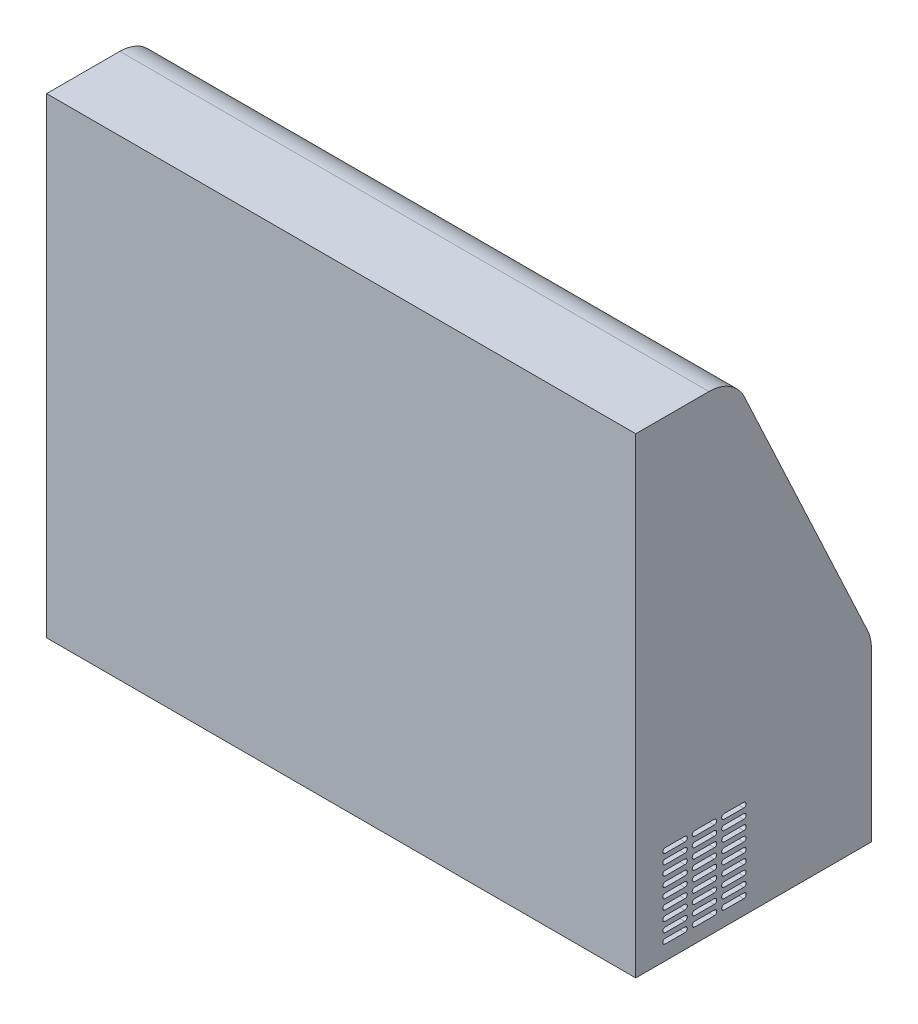
from build123d import *

# Parameters (mm, degrees)
SKETCH1_W               = 762
SKETCH1_H               = 609.6
BOSS_EXTRUDE1_DEPTH     = 304.8
SKETCH6_W               = 63.5
SKETCH6_H               = 122.2375
CUT_EXTRUDE3_DEPTH      = 12.7
CUT_EXTRUDE4_DEPTH      = 763
SKETCH8_W               = 549.402
SKETCH8_H               = 341.376
CUT_EXTRUDE5_DEPTH      = 50.8
CUT_EXTRUDE6_DEPTH      = 50.8
CUT_EXTRUDE7_DEPTH      = 50.8
CUT_EXTRUDE9_DEPTH      = 368.3
CUT_EXTRUDE9_DEPTH_BACK = 368.3


with BuildPart() as part:
    # Sketch1 → Boss-Extrude1 (new body)
    with BuildSketch(Plane.XY):
        Rectangle(SKETCH1_W, SKETCH1_H)
    extrude(amount=BOSS_EXTRUDE1_DEPTH)

    # Sketch6 → Cut-Extrude3 (cut)
    with BuildSketch(Plane(origin=(0, 0, 0), x_dir=(-1, 0, 0), z_dir=(0, 0, -1))):
        with Locations((289.814, -197.305909488)):
            Rectangle(SKETCH6_W, SKETCH6_H)
    extrude(amount=-CUT_EXTRUDE3_DEPTH, mode=Mode.SUBTRACT)

    # Sketch7 → Cut-Extrude4 (cut, through all)
    with BuildSketch(Plane(origin=(381, 0, 0), x_dir=(0, 0, -1), z_dir=(1, 0, 0))):
        with BuildLine():
            Line((-210.15264161, 304.8), (0, 304.8))
            Line((0, 304.8), (0, -87.469946307))
            ThreePointArc((0, -87.469946307), (-1.205784317, -76.467502451), (-4.765896488, -65.987364668))
            Line((-4.765896488, -65.987364668), (-164.118538098, 275.482581639))
            ThreePointArc((-164.118538098, 275.482581639), (-182.864138053, 296.848308877), (-210.15264161, 304.8))
        make_face()
    extrude(amount=-CUT_EXTRUDE4_DEPTH, mode=Mode.SUBTRACT)

    # Sketch8 → Cut-Extrude5 (cut)
    with BuildSketch(Plane(origin=(0, -13.627007299, 29.200729927), x_dir=(-1, 0, 0), z_dir=(0, 0.422885465, -0.90618314))):
        with Locations((0, 130.629903118)):
            Rectangle(SKETCH8_W, SKETCH8_H)
    extrude(amount=-CUT_EXTRUDE5_DEPTH, mode=Mode.SUBTRACT)

    # Sketch11 → Cut-Extrude6 (cut)
    with BuildSketch(Plane(origin=(381, 0, 0), x_dir=(0, 0, -1), z_dir=(1, 0, 0))):
        with BuildLine():
            Line((-228.6, -177.8), (-203.2, -177.8))
            ThreePointArc((-203.2, -177.8), (-200.025, -180.975), (-203.2, -184.15))
            Line((-203.2, -184.15), (-228.6, -184.15))
            ThreePointArc((-228.6, -184.15), (-231.775, -180.975), (-228.6, -177.8))
        make_face()
        with BuildLine():
            Line((-190.5, -177.8), (-165.1, -177.8))
            ThreePointArc((-165.1, -177.8), (-161.925, -180.975), (-165.1, -184.15))
            Line((-165.1, -184.15), (-190.5, -184.15))
            ThreePointArc((-190.5, -184.15), (-193.675, -180.975), (-190.5, -177.8))
        make_face()
        with BuildLine():
            Line((-228.6, -190.5), (-203.2, -190.5))
            ThreePointArc((-203.2, -190.5), (-200.025, -193.675), (-203.2, -196.85))
            Line((-203.2, -196.85), (-228.6, -196.85))
            ThreePointArc((-228.6, -196.85), (-231.775, -193.675), (-228.6, -190.5))
        make_face()
        with BuildLine():
            Line((-190.5, -190.5), (-165.1, -190.5))
            ThreePointArc((-165.1, -190.5), (-161.925, -193.675), (-165.1, -196.85))
            Line((-165.1, -196.85), (-190.5, -196.85))
            ThreePointArc((-190.5, -196.85), (-193.675, -193.675), (-190.5, -190.5))
        make_face()
        with BuildLine():
            Line((-228.6, -203.2), (-203.2, -203.2))
            ThreePointArc((-203.2, -203.2), (-200.025, -206.375), (-203.2, -209.55))
            Line((-203.2, -209.55), (-228.6, -209.55))
            ThreePointArc((-228.6, -209.55), (-231.775, -206.375), (-228.6, -203.2))
        make_face()
        with BuildLine():
            Line((-266.7, -177.8), (-241.3, -177.8))
            ThreePointArc((-241.3, -177.8), (-238.125, -180.975), (-241.3, -184.15))
            Line((-241.3, -184.15), (-266.7, -184.15))
            ThreePointArc((-266.7, -184.15), (-269.875, -180.975), (-266.7, -177.8))
        make_face()
        with BuildLine():
            Line((-190.5, -203.2), (-165.1, -203.2))
            ThreePointArc((-165.1, -203.2), (-161.925, -206.375), (-165.1, -209.55))
            Line((-165.1, -209.55), (-190.5, -209.55))
            ThreePointArc((-190.5, -209.55), (-193.675, -206.375), (-190.5, -203.2))
        make_face()
        with BuildLine():
            Line((-228.6, -215.9), (-203.2, -215.9))
            ThreePointArc((-203.2, -215.9), (-200.025, -219.075), (-203.2, -222.25))
            Line((-203.2, -222.25), (-228.6, -222.25))
            ThreePointArc((-228.6, -222.25), (-231.775, -219.075), (-228.6, -215.9))
        make_face()
        with BuildLine():
            Line((-190.5, -215.9), (-165.1, -215.9))
            ThreePointArc((-165.1, -215.9), (-161.925, -219.075), (-165.1, -222.25))
            Line((-165.1, -222.25), (-190.5, -222.25))
            ThreePointArc((-190.5, -222.25), (-193.675, -219.075), (-190.5, -215.9))
        make_face()
        with BuildLine():
            Line((-228.6, -228.6), (-203.2, -228.6))
            ThreePointArc((-203.2, -228.6), (-200.025, -231.775), (-203.2, -234.95))
            Line((-203.2, -234.95), (-228.6, -234.95))
            ThreePointArc((-228.6, -234.95), (-231.775, -231.775), (-228.6, -228.6))
        make_face()
        with BuildLine():
            Line((-190.5, -228.6), (-165.1, -228.6))
            ThreePointArc((-165.1, -228.6), (-161.925, -231.775), (-165.1, -234.95))
            Line((-165.1, -234.95), (-190.5, -234.95))
            ThreePointArc((-190.5, -234.95), (-193.675, -231.775), (-190.5, -228.6))
        make_face()
        with BuildLine():
            Line((-228.6, -241.3), (-203.2, -241.3))
            ThreePointArc((-203.2, -241.3), (-200.025, -244.475), (-203.2, -247.65))
            Line((-203.2, -247.65), (-228.6, -247.65))
            ThreePointArc((-228.6, -247.65), (-231.775, -244.475), (-228.6, -241.3))
        make_face()
        with BuildLine():
            Line((-190.5, -241.3), (-165.1, -241.3))
            ThreePointArc((-165.1, -241.3), (-161.925, -244.475), (-165.1, -247.65))
            Line((-165.1, -247.65), (-190.5, -247.65))
            ThreePointArc((-190.5, -247.65), (-193.675, -244.475), (-190.5, -241.3))
        make_face()
        with BuildLine():
            Line((-228.6, -254), (-203.2, -254))
            ThreePointArc((-203.2, -254), (-200.025, -257.175), (-203.2, -260.35))
            Line((-203.2, -260.35), (-228.6, -260.35))
            ThreePointArc((-228.6, -260.35), (-231.775, -257.175), (-228.6, -254))
        make_face()
        with BuildLine():
            Line((-190.5, -254), (-165.1, -254))
            ThreePointArc((-165.1, -254), (-161.925, -257.175), (-165.1, -260.35))
            Line((-165.1, -260.35), (-190.5, -260.35))
            ThreePointArc((-190.5, -260.35), (-193.675, -257.175), (-190.5, -254))
        make_face()
        with BuildLine():
            Line((-228.6, -266.7), (-203.2, -266.7))
            ThreePointArc((-203.2, -266.7), (-200.025, -269.875), (-203.2, -273.05))
            Line((-203.2, -273.05), (-228.6, -273.05))
            ThreePointArc((-228.6, -273.05), (-231.775, -269.875), (-228.6, -266.7))
        make_face()
        with BuildLine():
            Line((-190.5, -266.7), (-165.1, -266.7))
            ThreePointArc((-165.1, -266.7), (-161.925, -269.875), (-165.1, -273.05))
            Line((-165.1, -273.05), (-190.5, -273.05))
            ThreePointArc((-190.5, -273.05), (-193.675, -269.875), (-190.5, -266.7))
        make_face()
        with BuildLine():
            Line((-228.6, -279.4), (-203.2, -279.4))
            ThreePointArc((-203.2, -279.4), (-200.025, -282.575), (-203.2, -285.75))
            Line((-203.2, -285.75), (-228.6, -285.75))
            ThreePointArc((-228.6, -285.75), (-231.775, -282.575), (-228.6, -279.4))
        make_face()
        with BuildLine():
            Line((-190.5, -279.4), (-165.1, -279.4))
            ThreePointArc((-165.1, -279.4), (-161.925, -282.575), (-165.1, -285.75))
            Line((-165.1, -285.75), (-190.5, -285.75))
            ThreePointArc((-190.5, -285.75), (-193.675, -282.575), (-190.5, -279.4))
        make_face()
        with BuildLine():
            Line((-266.7, -190.5), (-241.3, -190.5))
            ThreePointArc((-241.3, -190.5), (-238.125, -193.675), (-241.3, -196.85))
            Line((-241.3, -196.85), (-266.7, -196.85))
            ThreePointArc((-266.7, -196.85), (-269.875, -193.675), (-266.7, -190.5))
        make_face()
        with BuildLine():
            Line((-266.7, -203.2), (-241.3, -203.2))
            ThreePointArc((-241.3, -203.2), (-238.125, -206.375), (-241.3, -209.55))
            Line((-241.3, -209.55), (-266.7, -209.55))
            ThreePointArc((-266.7, -209.55), (-269.875, -206.375), (-266.7, -203.2))
        make_face()
        with BuildLine():
            Line((-266.7, -215.9), (-241.3, -215.9))
            ThreePointArc((-241.3, -215.9), (-238.125, -219.075), (-241.3, -222.25))
            Line((-241.3, -222.25), (-266.7, -222.25))
            ThreePointArc((-266.7, -222.25), (-269.875, -219.075), (-266.7, -215.9))
        make_face()
        with BuildLine():
            Line((-266.7, -228.6), (-241.3, -228.6))
            ThreePointArc((-241.3, -228.6), (-238.125, -231.775), (-241.3, -234.95))
            Line((-241.3, -234.95), (-266.7, -234.95))
            ThreePointArc((-266.7, -234.95), (-269.875, -231.775), (-266.7, -228.6))
        make_face()
        with BuildLine():
            Line((-266.7, -241.3), (-241.3, -241.3))
            ThreePointArc((-241.3, -241.3), (-238.125, -244.475), (-241.3, -247.65))
            Line((-241.3, -247.65), (-266.7, -247.65))
            ThreePointArc((-266.7, -247.65), (-269.875, -244.475), (-266.7, -241.3))
        make_face()
        with BuildLine():
            Line((-266.7, -254), (-241.3, -254))
            ThreePointArc((-241.3, -254), (-238.125, -257.175), (-241.3, -260.35))
            Line((-241.3, -260.35), (-266.7, -260.35))
            ThreePointArc((-266.7, -260.35), (-269.875, -257.175), (-266.7, -254))
        make_face()
        with BuildLine():
            Line((-266.7, -266.7), (-241.3, -266.7))
            ThreePointArc((-241.3, -266.7), (-238.125, -269.875), (-241.3, -273.05))
            Line((-241.3, -273.05), (-266.7, -273.05))
            ThreePointArc((-266.7, -273.05), (-269.875, -269.875), (-266.7, -266.7))
        make_face()
        with BuildLine():
            Line((-266.7, -279.4), (-241.3, -279.4))
            ThreePointArc((-241.3, -279.4), (-238.125, -282.575), (-241.3, -285.75))
            Line((-241.3, -285.75), (-266.7, -285.75))
            ThreePointArc((-266.7, -285.75), (-269.875, -282.575), (-266.7, -279.4))
        make_face()
    extrude(amount=-CUT_EXTRUDE6_DEPTH, mode=Mode.SUBTRACT)

    # Sketch12 → Cut-Extrude7 (cut)
    with BuildSketch(Plane.XZ.offset(304.8)):
        with BuildLine():
            Line((-289.018463274, 250.918463274), (-263.618463274, 250.918463274))
            ThreePointArc((-263.618463274, 250.918463274), (-260.443463274, 247.743463274), (-263.618463274, 244.568463274))
            Line((-263.618463274, 244.568463274), (-289.018463274, 244.568463274))
            ThreePointArc((-289.018463274, 244.568463274), (-292.193463274, 247.743463274), (-289.018463274, 250.918463274))
        make_face()
        with BuildLine():
            Line((-250.918463274, 250.918463274), (-225.518463274, 250.918463274))
            ThreePointArc((-225.518463274, 250.918463274), (-222.343463274, 247.743463274), (-225.518463274, 244.568463274))
            Line((-225.518463274, 244.568463274), (-250.918463274, 244.568463274))
            ThreePointArc((-250.918463274, 244.568463274), (-254.093463274, 247.743463274), (-250.918463274, 250.918463274))
        make_face()
        with BuildLine():
            Line((-289.018463274, 238.218463274), (-263.618463274, 238.218463274))
            ThreePointArc((-263.618463274, 238.218463274), (-260.443463274, 235.043463274), (-263.618463274, 231.868463274))
            Line((-263.618463274, 231.868463274), (-289.018463274, 231.868463274))
            ThreePointArc((-289.018463274, 231.868463274), (-292.193463274, 235.043463274), (-289.018463274, 238.218463274))
        make_face()
        with BuildLine():
            Line((-250.918463274, 238.218463274), (-225.518463274, 238.218463274))
            ThreePointArc((-225.518463274, 238.218463274), (-222.343463274, 235.043463274), (-225.518463274, 231.868463274))
            Line((-225.518463274, 231.868463274), (-250.918463274, 231.868463274))
            ThreePointArc((-250.918463274, 231.868463274), (-254.093463274, 235.043463274), (-250.918463274, 238.218463274))
        make_face()
        with BuildLine():
            Line((-289.018463274, 225.518463274), (-263.618463274, 225.518463274))
            ThreePointArc((-263.618463274, 225.518463274), (-260.443463274, 222.343463274), (-263.618463274, 219.168463274))
            Line((-263.618463274, 219.168463274), (-289.018463274, 219.168463274))
            ThreePointArc((-289.018463274, 219.168463274), (-292.193463274, 222.343463274), (-289.018463274, 225.518463274))
        make_face()
        with BuildLine():
            Line((-327.118463274, 250.918463274), (-301.718463274, 250.918463274))
            ThreePointArc((-301.718463274, 250.918463274), (-298.543463274, 247.743463274), (-301.718463274, 244.568463274))
            Line((-301.718463274, 244.568463274), (-327.118463274, 244.568463274))
            ThreePointArc((-327.118463274, 244.568463274), (-330.293463274, 247.743463274), (-327.118463274, 250.918463274))
        make_face()
        with BuildLine():
            Line((-250.918463274, 225.518463274), (-225.518463274, 225.518463274))
            ThreePointArc((-225.518463274, 225.518463274), (-222.343463274, 222.343463274), (-225.518463274, 219.168463274))
            Line((-225.518463274, 219.168463274), (-250.918463274, 219.168463274))
            ThreePointArc((-250.918463274, 219.168463274), (-254.093463274, 222.343463274), (-250.918463274, 225.518463274))
        make_face()
        with BuildLine():
            Line((-289.018463274, 212.818463274), (-263.618463274, 212.818463274))
            ThreePointArc((-263.618463274, 212.818463274), (-260.443463274, 209.643463274), (-263.618463274, 206.468463274))
            Line((-263.618463274, 206.468463274), (-289.018463274, 206.468463274))
            ThreePointArc((-289.018463274, 206.468463274), (-292.193463274, 209.643463274), (-289.018463274, 212.818463274))
        make_face()
        with BuildLine():
            Line((-250.918463274, 212.818463274), (-225.518463274, 212.818463274))
            ThreePointArc((-225.518463274, 212.818463274), (-222.343463274, 209.643463274), (-225.518463274, 206.468463274))
            Line((-225.518463274, 206.468463274), (-250.918463274, 206.468463274))
            ThreePointArc((-250.918463274, 206.468463274), (-254.093463274, 209.643463274), (-250.918463274, 212.818463274))
        make_face()
        with BuildLine():
            Line((-289.018463274, 200.118463274), (-263.618463274, 200.118463274))
            ThreePointArc((-263.618463274, 200.118463274), (-260.443463274, 196.943463274), (-263.618463274, 193.768463274))
            Line((-263.618463274, 193.768463274), (-289.018463274, 193.768463274))
            ThreePointArc((-289.018463274, 193.768463274), (-292.193463274, 196.943463274), (-289.018463274, 200.118463274))
        make_face()
        with BuildLine():
            Line((-250.918461565, 200.118465114), (-225.518461565, 200.118465114))
            ThreePointArc((-225.518461565, 200.118465114), (-222.343461565, 196.943465114), (-225.518461565, 193.768465114))
            Line((-225.518461565, 193.768465114), (-250.918461565, 193.768465114))
            ThreePointArc((-250.918461565, 193.768465114), (-254.093461565, 196.943465114), (-250.918461565, 200.118465114))
        make_face()
        with BuildLine():
            Line((-289.018463274, 187.418463274), (-263.618463274, 187.418463274))
            ThreePointArc((-263.618463274, 187.418463274), (-260.443463274, 184.243463274), (-263.618463274, 181.068463274))
            Line((-263.618463274, 181.068463274), (-289.018463274, 181.068463274))
            ThreePointArc((-289.018463274, 181.068463274), (-292.193463274, 184.243463274), (-289.018463274, 187.418463274))
        make_face()
        with BuildLine():
            Line((-250.918463274, 187.418463274), (-225.518463274, 187.418463274))
            ThreePointArc((-225.518463274, 187.418463274), (-222.343463274, 184.243463274), (-225.518463274, 181.068463274))
            Line((-225.518463274, 181.068463274), (-250.918463274, 181.068463274))
            ThreePointArc((-250.918463274, 181.068463274), (-254.093463274, 184.243463274), (-250.918463274, 187.418463274))
        make_face()
        with BuildLine():
            Line((-289.018463274, 174.718463274), (-263.618463274, 174.718463274))
            ThreePointArc((-263.618463274, 174.718463274), (-260.443463274, 171.543463274), (-263.618463274, 168.368463274))
            Line((-263.618463274, 168.368463274), (-289.018463274, 168.368463274))
            ThreePointArc((-289.018463274, 168.368463274), (-292.193463274, 171.543463274), (-289.018463274, 174.718463274))
        make_face()
        with BuildLine():
            Line((-250.918463274, 174.718463274), (-225.518463274, 174.718463274))
            ThreePointArc((-225.518463274, 174.718463274), (-222.343463274, 171.543463274), (-225.518463274, 168.368463274))
            Line((-225.518463274, 168.368463274), (-250.918463274, 168.368463274))
            ThreePointArc((-250.918463274, 168.368463274), (-254.093463274, 171.543463274), (-250.918463274, 174.718463274))
        make_face()
        with BuildLine():
            Line((-289.018463274, 162.018463274), (-263.618463274, 162.018463274))
            ThreePointArc((-263.618463274, 162.018463274), (-260.443463274, 158.843463274), (-263.618463274, 155.668463274))
            Line((-263.618463274, 155.668463274), (-289.018463274, 155.668463274))
            ThreePointArc((-289.018463274, 155.668463274), (-292.193463274, 158.843463274), (-289.018463274, 162.018463274))
        make_face()
        with BuildLine():
            Line((-250.918463274, 162.018463274), (-225.518463274, 162.018463274))
            ThreePointArc((-225.518463274, 162.018463274), (-222.343463274, 158.843463274), (-225.518463274, 155.668463274))
            Line((-225.518463274, 155.668463274), (-250.918463274, 155.668463274))
            ThreePointArc((-250.918463274, 155.668463274), (-254.093463274, 158.843463274), (-250.918463274, 162.018463274))
        make_face()
        with BuildLine():
            Line((-289.018463274, 149.318463274), (-263.618463274, 149.318463274))
            ThreePointArc((-263.618463274, 149.318463274), (-260.443463274, 146.143463274), (-263.618463274, 142.968463274))
            Line((-263.618463274, 142.968463274), (-289.018463274, 142.968463274))
            ThreePointArc((-289.018463274, 142.968463274), (-292.193463274, 146.143463274), (-289.018463274, 149.318463274))
        make_face()
        with BuildLine():
            Line((-250.918463274, 149.318463274), (-225.518463274, 149.318463274))
            ThreePointArc((-225.518463274, 149.318463274), (-222.343463274, 146.143463274), (-225.518463274, 142.968463274))
            Line((-225.518463274, 142.968463274), (-250.918463274, 142.968463274))
            ThreePointArc((-250.918463274, 142.968463274), (-254.093463274, 146.143463274), (-250.918463274, 149.318463274))
        make_face()
        with BuildLine():
            Line((-327.118463274, 238.218463274), (-301.718463274, 238.218463274))
            ThreePointArc((-301.718463274, 238.218463274), (-298.543463274, 235.043463274), (-301.718463274, 231.868463274))
            Line((-301.718463274, 231.868463274), (-327.118463274, 231.868463274))
            ThreePointArc((-327.118463274, 231.868463274), (-330.293463274, 235.043463274), (-327.118463274, 238.218463274))
        make_face()
        with BuildLine():
            Line((-327.118463274, 225.518463274), (-301.718463274, 225.518463274))
            ThreePointArc((-301.718463274, 225.518463274), (-298.543463274, 222.343463274), (-301.718463274, 219.168463274))
            Line((-301.718463274, 219.168463274), (-327.118463274, 219.168463274))
            ThreePointArc((-327.118463274, 219.168463274), (-330.293463274, 222.343463274), (-327.118463274, 225.518463274))
        make_face()
        with BuildLine():
            Line((-327.118463274, 212.818463274), (-301.718463274, 212.818463274))
            ThreePointArc((-301.718463274, 212.818463274), (-298.543463274, 209.643463274), (-301.718463274, 206.468463274))
            Line((-301.718463274, 206.468463274), (-327.118463274, 206.468463274))
            ThreePointArc((-327.118463274, 206.468463274), (-330.293463274, 209.643463274), (-327.118463274, 212.818463274))
        make_face()
        with BuildLine():
            Line((-327.118463274, 200.118463274), (-301.718463274, 200.118463274))
            ThreePointArc((-301.718463274, 200.118463274), (-298.543463274, 196.943463274), (-301.718463274, 193.768463274))
            Line((-301.718463274, 193.768463274), (-327.118463274, 193.768463274))
            ThreePointArc((-327.118463274, 193.768463274), (-330.293463274, 196.943463274), (-327.118463274, 200.118463274))
        make_face()
        with BuildLine():
            Line((-327.118463274, 187.418463274), (-301.718463274, 187.418463274))
            ThreePointArc((-301.718463274, 187.418463274), (-298.543463274, 184.243463274), (-301.718463274, 181.068463274))
            Line((-301.718463274, 181.068463274), (-327.118463274, 181.068463274))
            ThreePointArc((-327.118463274, 181.068463274), (-330.293463274, 184.243463274), (-327.118463274, 187.418463274))
        make_face()
        with BuildLine():
            Line((-327.118463274, 174.718463274), (-301.718463274, 174.718463274))
            ThreePointArc((-301.718463274, 174.718463274), (-298.543463274, 171.543463274), (-301.718463274, 168.368463274))
            Line((-301.718463274, 168.368463274), (-327.118463274, 168.368463274))
            ThreePointArc((-327.118463274, 168.368463274), (-330.293463274, 171.543463274), (-327.118463274, 174.718463274))
        make_face()
        with BuildLine():
            Line((-327.118463274, 162.018463274), (-301.718463274, 162.018463274))
            ThreePointArc((-301.718463274, 162.018463274), (-298.543463274, 158.843463274), (-301.718463274, 155.668463274))
            Line((-301.718463274, 155.668463274), (-327.118463274, 155.668463274))
            ThreePointArc((-327.118463274, 155.668463274), (-330.293463274, 158.843463274), (-327.118463274, 162.018463274))
        make_face()
        with BuildLine():
            Line((-327.118463274, 149.318463274), (-301.718463274, 149.318463274))
            ThreePointArc((-301.718463274, 149.318463274), (-298.543463274, 146.143463274), (-301.718463274, 142.968463274))
            Line((-301.718463274, 142.968463274), (-327.118463274, 142.968463274))
            ThreePointArc((-327.118463274, 142.968463274), (-330.293463274, 146.143463274), (-327.118463274, 149.318463274))
        make_face()
    extrude(amount=-CUT_EXTRUDE7_DEPTH, mode=Mode.SUBTRACT)

    # Sketch15 → Cut-Extrude9 (cut, two sides)
    with BuildSketch(Plane(origin=(0, 0, 0), x_dir=(0, 0, -1), z_dir=(1, 0, 0))) as cut_extrude9_sk:
        with BuildLine():
            Line((-62.308525878, -92.840591717), (-221.661167488, 248.62935459))
            Line((-221.661167488, 248.62935459), (-175.627063976, 270.111936229))
            ThreePointArc((-175.627063976, 270.111936229), (-189.686263942, 286.136231658), (-210.15264161, 292.1))
            Line((-210.15264161, 292.1), (-292.1, 292.1))
            Line((-292.1, 292.1), (-292.1, -292.1))
            Line((-292.1, -292.1), (-12.7, -292.1))
            Line((-12.7, -292.1), (-12.7, -87.469946307))
            ThreePointArc((-12.7, -87.469946307), (-13.604338238, -79.218113415), (-16.274422366, -71.358010078))
            Line((-16.274422366, -71.358010078), (-62.308525878, -92.840591717))
        make_face()
    extrude(amount=CUT_EXTRUDE9_DEPTH, mode=Mode.SUBTRACT)
    extrude(cut_extrude9_sk.sketch, amount=-CUT_EXTRUDE9_DEPTH_BACK, mode=Mode.SUBTRACT)


solid = part.part
